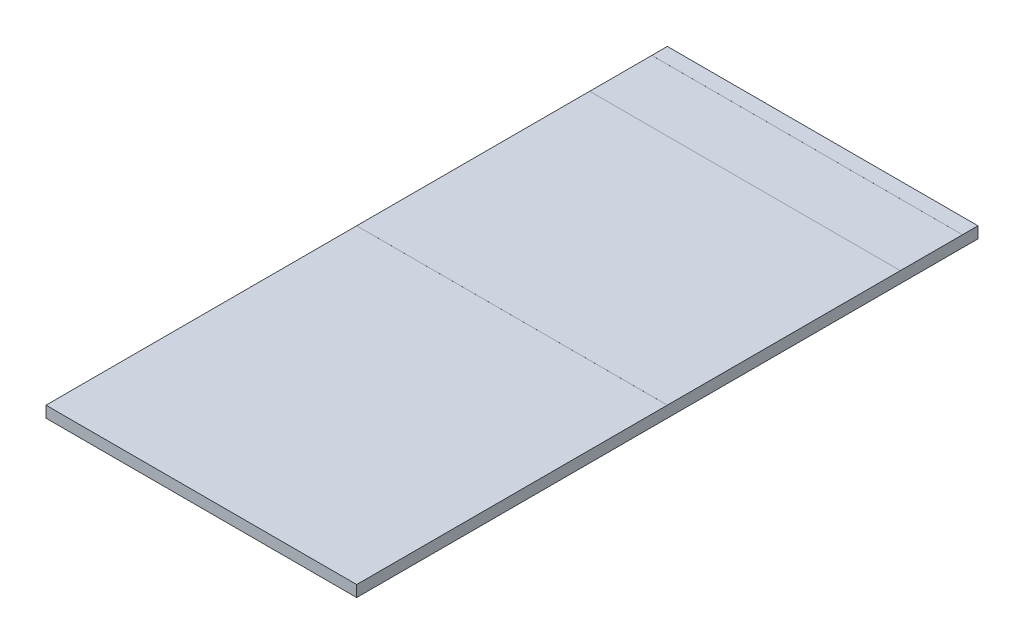
from build123d import *

# Parameters (mm, degrees)
SKETCH1_W           = 2
SKETCH1_H           = 0.072865
BOSS_EXTRUDE1_DEPTH = 4
SKETCH7_W           = 2
SKETCH7_H           = 0.1
SKETCH7_H_2         = 1.5
BOSS_EXTRUDE6_DEPTH = 0.0001
BOSS_EXTRUDE7_START = -0.072865
SKETCH7_2_W         = 2
SKETCH7_2_H         = 0.1
SKETCH7_2_H_2       = 1.5
BOSS_EXTRUDE7_DEPTH = 0.0001


with BuildPart() as part:
    # Sketch1 → Boss-Extrude1 (new body)
    with BuildSketch(Plane.XY):
        with Locations((1, 0.0364325)):
            Rectangle(SKETCH1_W, SKETCH1_H)
    extrude(amount=BOSS_EXTRUDE1_DEPTH)

    # Sketch7 → Boss-Extrude6 (add)
    with BuildSketch(Plane(origin=(0, 0.072865, 0), x_dir=(1, 0, 0), z_dir=(0, 1, 0))):
        with Locations((1, -0.05)):
            Rectangle(SKETCH7_W, SKETCH7_H)
        with Locations((1, -1.25)):
            Rectangle(SKETCH7_W, SKETCH7_H_2)
    extrude(amount=BOSS_EXTRUDE6_DEPTH)

    # Sketch7_2 → Boss-Extrude7 (add)
    with BuildSketch(Plane(origin=(0, 0.072865, 0), x_dir=(1, 0, 0), z_dir=(0, 1, 0)).offset(BOSS_EXTRUDE7_START)):
        with Locations((1, -0.05)):
            Rectangle(SKETCH7_2_W, SKETCH7_2_H)
        with Locations((1, -1.25)):
            Rectangle(SKETCH7_2_W, SKETCH7_2_H_2)
    extrude(amount=-BOSS_EXTRUDE7_DEPTH)


solid = part.part
